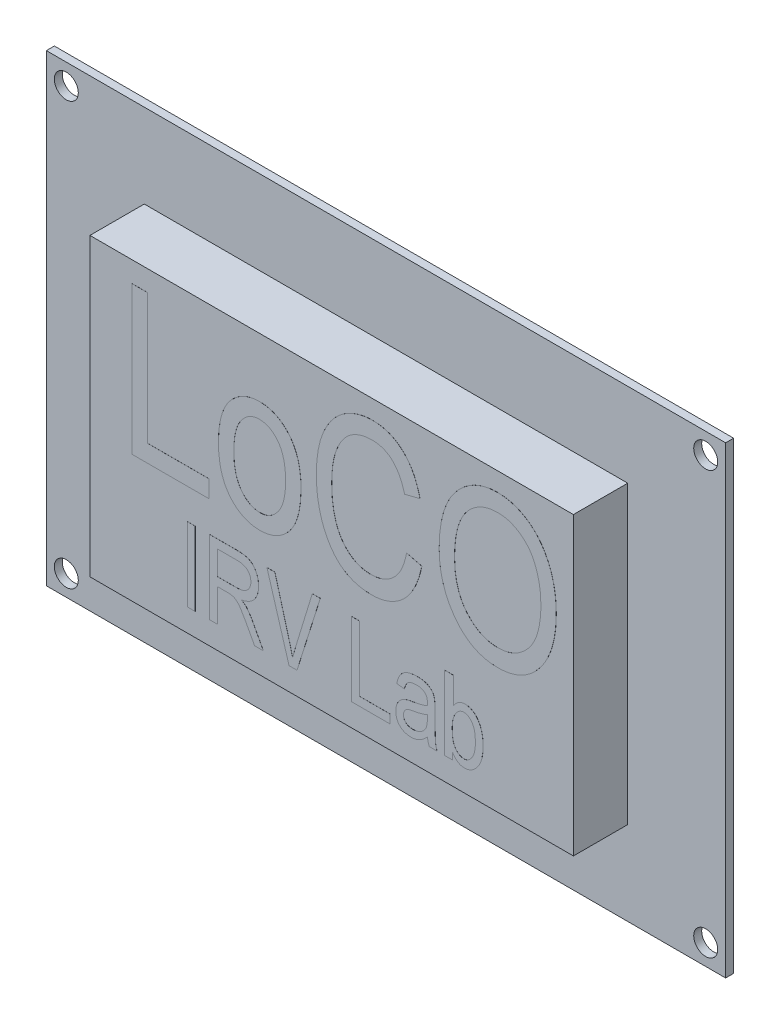
from build123d import *

# Parameters (mm, degrees)
SKETCH2_W           = 85
SKETCH2_H           = 58
SKETCH2_R           = 1.5
BOSS_EXTRUDE1_DEPTH = 1
SKETCH3_W           = 60.5
SKETCH3_H           = 37
BOSS_EXTRUDE2_DEPTH = 6.8
BOSS_EXTRUDE3_DEPTH = 0.01
SKETCH7_W           = 0.960617898
SKETCH7_H           = 9.245947265
BOSS_EXTRUDE4_DEPTH = 0.01


with BuildPart() as part:
    # Sketch2 → Boss-Extrude1 (new body)
    with BuildSketch(Plane.XY):
        Rectangle(SKETCH2_W, SKETCH2_H)
        with Locations((-40.005, 26.415)):
            Circle(SKETCH2_R, mode=Mode.SUBTRACT)
        with Locations((-40.005, -26.417)):
            Circle(SKETCH2_R, mode=Mode.SUBTRACT)
        with Locations((40.005, -26.417)):
            Circle(SKETCH2_R, mode=Mode.SUBTRACT)
        with Locations((40.005, 26.415)):
            Circle(SKETCH2_R, mode=Mode.SUBTRACT)
    extrude(amount=BOSS_EXTRUDE1_DEPTH)

    # Sketch3 → Boss-Extrude2 (add)
    with BuildSketch(Plane.XY.offset(1)):
        Rectangle(SKETCH3_W, SKETCH3_H)
    extrude(amount=BOSS_EXTRUDE2_DEPTH)

    # Sketch6 → Boss-Extrude3 (add)
    with BuildSketch(Plane.XY.offset(7.8)):
        Polygon((-24.963170893, -2.578067019), (-24.963170893, 15.913827512), (-23.041935097, 15.913827512), (-23.041935097, -0.416676749), (-15.356991915, -0.416676749), (-15.356991915, -2.578067019), align=None)
        with BuildLine():
            add(Edge.make_bspline(
                [(-14.156219543, 4.146258265), (-14.15200696, 4.42530417), (-14.143833079, 4.966750577), (-14.077886357, 5.752032324), (-13.959388452, 6.483464237), (-13.806933902, 7.164302864), (-13.597996615, 7.791479774), (-13.349059179, 8.367491571), (-13.05094873, 8.889941904), (-12.708280505, 9.357113515), (-12.329198324, 9.768007717), (-11.926500768, 10.129361278), (-11.495391443, 10.430018117), (-11.043726239, 10.680740051), (-10.565643457, 10.87298786), (-10.063826958, 11.012499727), (-9.536112732, 11.096979035), (-9.175826053, 11.106104677), (-8.992898343, 11.110738023)],
                knots=[0, 0, 0, 0, 0.000837091, 0.001624249, 0.002361452, 0.003058685, 0.003714885, 0.004341639, 0.00493832, 0.005515473, 0.00607584, 0.006612763, 0.00713536, 0.007649263, 0.008159329, 0.008677352, 0.009209137, 0.009757619, 0.009757619, 0.009757619, 0.009757619], degree=3))
            add(Edge.make_bspline(
                [(-8.992898343, 11.110738023), (-8.812454083, 11.106205822), (-8.45834284, 11.097311643), (-7.938284473, 11.011669197), (-7.441705544, 10.872185185), (-6.965245286, 10.681817127), (-6.51609778, 10.428798594), (-6.085429031, 10.129588058), (-5.682439834, 9.767132369), (-5.301595354, 9.356527716), (-4.948921739, 8.895576641), (-4.651580836, 8.377372416), (-4.392704216, 7.814603207), (-4.189901258, 7.200704027), (-4.027950751, 6.540739186), (-3.913626128, 5.831799777), (-3.840605578, 5.074639691), (-3.833318488, 4.55294606), (-3.829577143, 4.28509757)],
                knots=[0, 0, 0, 0, 0.000540986, 0.001061652, 0.001576062, 0.002086128, 0.002596746, 0.003119343, 0.003656266, 0.004219178, 0.004797804, 0.005393115, 0.006007698, 0.006653222, 0.007329428, 0.008044408, 0.008805741, 0.009609073, 0.009609073, 0.009609073, 0.009609073], degree=3))
            add(Edge.make_bspline(
                [(-3.829577143, 4.28509757), (-3.83372774, 3.994794579), (-3.841754786, 3.433363293), (-3.908109211, 2.619427655), (-4.025777942, 1.864125963), (-4.178326976, 1.163278066), (-4.387336273, 0.522890075), (-4.632431151, -0.064253775), (-4.930172263, -0.592879833), (-5.272899155, -1.062810828), (-5.649105151, -1.476632145), (-6.051936918, -1.836727908), (-6.482906541, -2.137421542), (-6.935419002, -2.38921361), (-7.415486962, -2.579641695), (-7.918160424, -2.72012531), (-8.447185117, -2.804625323), (-8.808721004, -2.813632808), (-8.992898343, -2.818221494)],
                knots=[0, 0, 0, 0, 0.000870851, 0.001684182, 0.002447335, 0.003162856, 0.003833321, 0.004465478, 0.005068683, 0.005648865, 0.006206701, 0.006743624, 0.007266221, 0.007780124, 0.00829367, 0.008811694, 0.009343478, 0.009895708, 0.009895708, 0.009895708, 0.009895708], degree=3))
            add(Edge.make_bspline(
                [(-8.992898343, -2.818221494), (-9.173331556, -2.81355127), (-9.529892967, -2.80432225), (-10.05251669, -2.719760071), (-10.552643117, -2.58083849), (-11.027707661, -2.383398411), (-11.480083611, -2.135215604), (-11.909446242, -1.830660104), (-12.313207009, -1.469511051), (-12.692990872, -1.055936489), (-13.040862365, -0.589629356), (-13.340095479, -0.066175863), (-13.591659287, 0.511019439), (-13.801340629, 1.137236224), (-13.96261011, 1.816713799), (-14.070766036, 2.547504727), (-14.14577011, 3.329183176), (-14.152665912, 3.86838829), (-14.156219543, 4.146258265)],
                knots=[0, 0, 0, 0, 0.000540986, 0.001069064, 0.001583473, 0.002094959, 0.002608861, 0.003128391, 0.003670612, 0.004230979, 0.004810359, 0.005412163, 0.006035482, 0.006696429, 0.007390868, 0.008127489, 0.008911241, 0.009744581, 0.009744581, 0.009744581, 0.009744581], degree=3))
        make_face()
        with BuildLine():
            add(Edge.make_bspline(
                [(-12.234983748, 4.153763092), (-12.232450504, 3.947271009), (-12.22754643, 3.547525544), (-12.180120634, 2.969084748), (-12.113343146, 2.430334113), (-12.00606319, 1.934564649), (-11.877548363, 1.476014822), (-11.712396377, 1.060669531), (-11.520425586, 0.683823899), (-11.298972448, 0.349838158), (-11.054872356, 0.0565262), (-10.794382089, -0.195948995), (-10.52274285, -0.412699242), (-10.23659641, -0.591301609), (-9.933058714, -0.727053311), (-9.61555828, -0.82456985), (-9.284309685, -0.88743544), (-9.058221732, -0.893782426), (-8.944116965, -0.896985698)],
                knots=[0, 0, 0, 0, 0.00061933, 0.001198954, 0.001740264, 0.002246604, 0.002719259, 0.003167307, 0.003585192, 0.003985876, 0.00436687, 0.004727766, 0.005072355, 0.005407666, 0.005736854, 0.00606681, 0.006402436, 0.006744421, 0.006744421, 0.006744421, 0.006744421], degree=3))
            add(Edge.make_bspline(
                [(-8.944116965, -0.896985698), (-8.836248049, -0.893786928), (-8.622535141, -0.887449435), (-8.309930092, -0.824513726), (-8.00832716, -0.72615972), (-7.71954674, -0.586973684), (-7.44336105, -0.406516858), (-7.175100581, -0.193417028), (-6.923411566, 0.065787255), (-6.684208241, 0.361687579), (-6.460497765, 0.695665177), (-6.269875095, 1.074180599), (-6.109114441, 1.491833763), (-5.979996093, 1.948333242), (-5.872038561, 2.442767551), (-5.805980242, 2.979120773), (-5.758289445, 3.553770423), (-5.753354887, 3.949770653), (-5.750812938, 4.153763092)],
                knots=[0, 0, 0, 0, 0.000323253, 0.000640437, 0.00095252, 0.001273082, 0.001598873, 0.001940528, 0.002298741, 0.002680253, 0.003080936, 0.00350216, 0.003948839, 0.004421494, 0.004924164, 0.005465475, 0.006041357, 0.006653185, 0.006653185, 0.006653185, 0.006653185], degree=3))
            add(Edge.make_bspline(
                [(-5.750812938, 4.153763092), (-5.753353214, 4.35900363), (-5.758269954, 4.756249493), (-5.80557462, 5.330962967), (-5.87289182, 5.867125225), (-5.979254359, 6.360555409), (-6.10792087, 6.816749727), (-6.275489292, 7.229587999), (-6.463064833, 7.607524387), (-6.687989894, 7.939496376), (-6.932056998, 8.232258091), (-7.190145137, 8.48853281), (-7.463202427, 8.705059774), (-7.749161727, 8.883858609), (-8.052748237, 9.019559063), (-8.370235615, 9.11708931), (-8.701487719, 9.179951215), (-8.927575195, 9.186298702), (-9.041679721, 9.189502228)],
                knots=[0, 0, 0, 0, 0.000615579, 0.001191461, 0.001729053, 0.002235392, 0.002704444, 0.003149006, 0.00357023, 0.003967791, 0.004348786, 0.004712305, 0.005056895, 0.005392206, 0.005721393, 0.00605135, 0.006386976, 0.006728961, 0.006728961, 0.006728961, 0.006728961], degree=3))
            add(Edge.make_bspline(
                [(-9.041679721, 9.189502228), (-9.150810717, 9.18639516), (-9.365797338, 9.180274276), (-9.680732178, 9.11656275), (-9.983174033, 9.018904419), (-10.274991847, 8.882571941), (-10.55408203, 8.705255233), (-10.81718142, 8.484299147), (-11.068748391, 8.227254057), (-11.310841244, 7.935424159), (-11.52716356, 7.599917761), (-11.720194208, 7.226253856), (-11.880692311, 6.810797866), (-12.010671335, 6.355937077), (-12.111995092, 5.861652701), (-12.1805457, 5.327284399), (-12.227334357, 4.753723985), (-12.23238302, 4.357744727), (-12.234983748, 4.153763092)],
                knots=[0, 0, 0, 0, 0.000326999, 0.000644183, 0.000959832, 0.001278787, 0.001607739, 0.001948858, 0.002307071, 0.002685675, 0.003084297, 0.003502182, 0.003945364, 0.004418019, 0.004919918, 0.005457509, 0.006033392, 0.006645219, 0.006645219, 0.006645219, 0.006645219], degree=3))
        make_face(mode=Mode.SUBTRACT)
        with BuildLine():
            Line((9.378918951, 3.90610379), (11.300154747, 3.425794842))
            add(Edge.make_bspline(
                [(11.300154747, 3.425794842), (11.242891984, 3.171195833), (11.131253485, 2.67483398), (10.921856518, 1.960903479), (10.677171533, 1.298320529), (10.403899049, 0.684575004), (10.099847744, 0.119572764), (9.766514302, -0.396297564), (9.401092804, -0.862614323), (9.001763057, -1.273635186), (8.581855362, -1.642429765), (8.131589248, -1.951997003), (7.664511209, -2.22330435), (7.171696954, -2.439388925), (6.658120736, -2.610538041), (6.121017661, -2.728604713), (5.562570016, -2.807723869), (5.181497307, -2.814693437), (4.988594965, -2.818221494)],
                knots=[0, 0, 0, 0, 0.000782745, 0.001526026, 0.002230051, 0.002900233, 0.003539917, 0.004152952, 0.004740753, 0.005313976, 0.005869954, 0.006414378, 0.006950553, 0.007488144, 0.008025683, 0.008571888, 0.009136012, 0.009714322, 0.009714322, 0.009714322, 0.009714322], degree=3))
            add(Edge.make_bspline(
                [(4.988594965, -2.818221494), (4.81834251, -2.815872259), (4.484607751, -2.811267208), (3.993471036, -2.759209824), (3.520035056, -2.683170333), (3.065395889, -2.568691242), (2.628552016, -2.428545701), (2.213721161, -2.248558067), (1.814162689, -2.043719818), (1.434449818, -1.801642875), (1.070071269, -1.527400983), (0.730805893, -1.208537913), (0.400243033, -0.859984297), (0.095322455, -0.465085077), (-0.204654032, -0.039584319), (-0.474337021, 0.432427386), (-0.735961693, 0.93714066), (-0.976896507, 1.4786138), (-1.201311201, 2.05140184), (-1.384574701, 2.656355206), (-1.548025031, 3.282945285), (-1.677747425, 3.936028511), (-1.784779462, 4.612891574), (-1.852558442, 5.31720806), (-1.90046331, 6.045568257), (-1.905685973, 6.540215103), (-1.908341347, 6.791709897)],
                knots=[0, 0, 0, 0, 0.000510549, 0.001000796, 0.001480122, 0.001947911, 0.002405951, 0.002854816, 0.003302927, 0.003751603, 0.004204154, 0.004668863, 0.005146733, 0.005643697, 0.006164148, 0.006707328, 0.007272898, 0.007869166, 0.008484493, 0.009117095, 0.009764188, 0.010426507, 0.011113773, 0.011819087, 0.012548447, 0.013302831, 0.013302831, 0.013302831, 0.013302831], degree=3))
            add(Edge.make_bspline(
                [(-1.908341347, 6.791709897), (-1.905707656, 7.039454752), (-1.900542166, 7.525359656), (-1.852715737, 8.238728047), (-1.785109223, 8.924369484), (-1.677700067, 9.579930681), (-1.548865058, 10.208264244), (-1.386024855, 10.805188528), (-1.200019012, 11.375614435), (-0.978835724, 11.914086842), (-0.729590688, 12.421034838), (-0.463251486, 12.898567852), (-0.179200745, 13.346729203), (0.129063121, 13.760927932), (0.459894368, 14.140135586), (0.810607883, 14.488149668), (1.183024834, 14.802805655), (1.572836044, 15.089797288), (1.981322581, 15.338530766), (2.400059856, 15.559420008), (2.832197948, 15.742698545), (3.276159764, 15.893306221), (3.731516184, 16.010377913), (4.198438775, 16.090870372), (4.675751684, 16.147643686), (4.998431647, 16.151856735), (5.161205994, 16.153981986)],
                knots=[0, 0, 0, 0, 0.00074313, 0.001457509, 0.002144159, 0.002809184, 0.003449452, 0.004067519, 0.004664389, 0.005248332, 0.005812206, 0.006358179, 0.006888014, 0.007402848, 0.007905517, 0.008396395, 0.008883588, 0.009366936, 0.00984704, 0.010316991, 0.010786058, 0.011253591, 0.011722298, 0.012194864, 0.012674307, 0.013162352, 0.013162352, 0.013162352, 0.013162352], degree=3))
            add(Edge.make_bspline(
                [(5.161205994, 16.153981986), (5.338979024, 16.149379478), (5.688185591, 16.140338589), (6.203979813, 16.077027341), (6.697394832, 15.961878993), (7.176730584, 15.813529312), (7.632991827, 15.612986256), (8.072073678, 15.371718091), (8.4901465, 15.084639533), (8.887483281, 14.753518824), (9.263652631, 14.382454688), (9.61013372, 13.967559972), (9.923763583, 13.510674107), (10.216731064, 13.018194216), (10.469060884, 12.478116787), (10.696570157, 11.899939589), (10.903711868, 11.282675352), (11.00702934, 10.851495338), (11.060000272, 10.630429074)],
                knots=[0, 0, 0, 0, 0.000533318, 0.001047618, 0.001555568, 0.002051625, 0.002550752, 0.003047887, 0.003552681, 0.004069643, 0.004597668, 0.00513577, 0.005688496, 0.006258691, 0.006852865, 0.007474419, 0.008122316, 0.008803987, 0.008803987, 0.008803987, 0.008803987], degree=3))
            Line((11.060000272, 10.630429074), (9.138764477, 10.150120126))
            add(Edge.make_bspline(
                [(9.138764477, 10.150120126), (9.095340635, 10.305706881), (9.010651095, 10.609147806), (8.859943659, 11.044981467), (8.695111189, 11.451057618), (8.515970021, 11.828472598), (8.316481805, 12.173951396), (8.10247705, 12.490309359), (7.873589465, 12.77842719), (7.625011427, 13.032229672), (7.365015968, 13.261230412), (7.085636003, 13.457405204), (6.789191198, 13.621291094), (6.478360354, 13.759057134), (6.152161213, 13.86268177), (5.809521155, 13.93900893), (5.45135091, 13.984030592), (5.206360359, 13.989715426), (5.082405307, 13.992591717)],
                knots=[0, 0, 0, 0, 0.000484512, 0.000944944, 0.001382547, 0.001798777, 0.002197188, 0.002578108, 0.002943791, 0.00329938, 0.003642495, 0.003981876, 0.004321195, 0.00465724, 0.005000191, 0.005346146, 0.005709182, 0.006080974, 0.006080974, 0.006080974, 0.006080974], degree=3))
            add(Edge.make_bspline(
                [(5.082405307, 13.992591717), (4.837742501, 13.983527205), (4.360320146, 13.965839187), (3.669822746, 13.81870777), (3.027353904, 13.583365445), (2.538367893, 13.300968942), (2.175813823, 13.030108462), (1.918829142, 12.798543546), (1.676855588, 12.540030658), (1.446947434, 12.25703154), (1.229166146, 11.94723148), (1.032773437, 11.606858969), (0.842307438, 11.245570288), (0.670677214, 10.855653403), (0.517777755, 10.439252345), (0.38178282, 9.997268251), (0.265793877, 9.528918919), (0.172231683, 9.032778788), (0.102665181, 8.510250648), (0.049029802, 7.960904655), (0.020229812, 7.384900699), (0.015369577, 6.991866837), (0.012894448, 6.791709897)],
                knots=[0, 0, 0, 0, 0.000733345, 0.001431011, 0.002107799, 0.002778485, 0.003116202, 0.003464288, 0.003814692, 0.004177455, 0.004557414, 0.004949339, 0.005355502, 0.005782223, 0.006226246, 0.006685591, 0.007168852, 0.007672976, 0.008199411, 0.008749777, 0.009328428, 0.009928919, 0.009928919, 0.009928919, 0.009928919], degree=3))
            add(Edge.make_bspline(
                [(0.012894448, 6.791709897), (0.017640417, 6.491422667), (0.026845573, 5.90899342), (0.085541216, 5.063116161), (0.188232578, 4.274249793), (0.3389836, 3.545024047), (0.525193112, 2.873092353), (0.751745808, 2.258197682), (1.027229345, 1.702921596), (1.341956148, 1.206108999), (1.693117093, 0.768118446), (2.071998531, 0.386511124), (2.480991656, 0.065185681), (2.915129026, -0.201987259), (3.38087477, -0.404073192), (3.871689413, -0.551895533), (4.391337528, -0.6395852), (4.746854491, -0.650998155), (4.928556347, -0.656831224)],
                knots=[0, 0, 0, 0, 0.000900861, 0.001747286, 0.002542266, 0.003285547, 0.003979328, 0.004632399, 0.005248275, 0.005835381, 0.00639328, 0.006929258, 0.00744498, 0.007950164, 0.008454232, 0.008963525, 0.0094848, 0.010029727, 0.010029727, 0.010029727, 0.010029727], degree=3))
            add(Edge.make_bspline(
                [(4.928556347, -0.656831224), (5.063826777, -0.653110867), (5.330391938, -0.645779499), (5.723382007, -0.59101568), (6.103508182, -0.506334954), (6.469807269, -0.382053739), (6.818334208, -0.218242521), (7.156121875, -0.027523751), (7.47619159, 0.204879925), (7.783018769, 0.469281868), (8.070292258, 0.771688504), (8.332911435, 1.111782777), (8.57483811, 1.486793144), (8.782379904, 1.902917469), (8.971104002, 2.351435727), (9.135849669, 2.836482131), (9.274928691, 3.358053929), (9.343698119, 3.720482827), (9.378918951, 3.90610379)],
                knots=[0, 0, 0, 0, 0.000405695, 0.000799466, 0.001188162, 0.001572634, 0.001957105, 0.002342016, 0.002734605, 0.003141616, 0.003555676, 0.003983517, 0.004429028, 0.004892204, 0.005376557, 0.005888001, 0.006427749, 0.006994401, 0.006994401, 0.006994401, 0.006994401], degree=3))
        make_face()
        with BuildLine():
            add(Edge.make_bspline(
                [(13.461545016, 6.423973358), (13.468076656, 6.803167112), (13.480796167, 7.541597248), (13.57775289, 8.615207931), (13.742453034, 9.620928945), (13.968655831, 10.559725719), (14.265862539, 11.429910189), (14.625237359, 12.234860717), (15.054539922, 12.97082865), (15.547494094, 13.634587309), (16.085222571, 14.227352219), (16.664061654, 14.741118555), (17.271823275, 15.180473285), (17.916041146, 15.533834039), (18.588420674, 15.818077216), (19.298362564, 16.008324633), (20.037455699, 16.135505617), (20.541803204, 16.147765879), (20.797513728, 16.153981986)],
                knots=[0, 0, 0, 0, 0.001137483, 0.002215099, 0.003230506, 0.004192486, 0.005108583, 0.005985275, 0.006832864, 0.007659162, 0.008461337, 0.009229482, 0.009977146, 0.01070608, 0.01142943, 0.012161372, 0.012906583, 0.013672995, 0.013672995, 0.013672995, 0.013672995], degree=3))
            add(Edge.make_bspline(
                [(20.797513728, 16.153981986), (20.965274718, 16.15026731), (21.296616126, 16.142930525), (21.787987196, 16.087680997), (22.267958747, 16.004172763), (22.736111383, 15.877123773), (23.195006199, 15.721049487), (23.641227214, 15.52527418), (24.075079387, 15.293564801), (24.498329741, 15.033288504), (24.904488732, 14.735471328), (25.29039015, 14.405210278), (25.656589017, 14.043860215), (25.997246426, 13.64856494), (26.31803858, 13.223081327), (26.613619566, 12.76447276), (26.888031045, 12.273884415), (27.142497803, 11.754605952), (27.371528405, 11.206178559), (27.571700634, 10.631530789), (27.733918252, 10.028616473), (27.875175537, 9.403345373), (27.977408043, 8.749877554), (28.057862306, 8.072966066), (28.102381734, 7.368933231), (28.108072776, 6.891831968), (28.110967957, 6.649118178)],
                knots=[0, 0, 0, 0, 0.000503173, 0.000993808, 0.001481809, 0.001963304, 0.002447467, 0.002934775, 0.003423253, 0.003922041, 0.00442415, 0.004932502, 0.005444607, 0.00596599, 0.006496582, 0.007041974, 0.007601436, 0.008182091, 0.008775839, 0.009383428, 0.010006103, 0.010647952, 0.011305567, 0.01198931, 0.012692455, 0.013420578, 0.013420578, 0.013420578, 0.013420578], degree=3))
            add(Edge.make_bspline(
                [(28.110967957, 6.649118178), (28.104930185, 6.317501513), (28.093106915, 5.668123977), (28.008691112, 4.71700302), (27.855177803, 3.814203804), (27.65780352, 2.955109261), (27.389016305, 2.146444006), (27.065414747, 1.384120771), (26.685790505, 0.665954831), (26.379404799, 0.225882247), (26.227256298, 0.007345995)],
                knots=[0, 0, 0, 0, 0.000994843, 0.001948118, 0.00286112, 0.003740338, 0.00458996, 0.005413783, 0.006222983, 0.007021225, 0.007021225, 0.007021225, 0.007021225], degree=3))
            add(Edge.make_bspline(
                [(26.227256298, 0.007345995), (26.051739025, -0.216740105), (25.708669651, -0.654743022), (25.125152864, -1.23386052), (24.501272399, -1.722901223), (23.838139063, -2.128324587), (23.131158337, -2.435387954), (22.385952551, -2.658999218), (21.599066528, -2.792606485), (21.06069858, -2.809572687), (20.786256487, -2.818221494)],
                knots=[0, 0, 0, 0, 0.000853309, 0.001667894, 0.002459075, 0.003226818, 0.003993018, 0.004764684, 0.005556159, 0.00637917, 0.00637917, 0.00637917, 0.00637917], degree=3))
            add(Edge.make_bspline(
                [(20.786256487, -2.818221494), (20.510525711, -2.809874681), (19.969387732, -2.793493567), (19.177250251, -2.655180086), (18.427965899, -2.425405812), (17.717491308, -2.108520466), (17.053048559, -1.694595438), (16.431031707, -1.190457628), (15.847483973, -0.598588945), (15.507862405, -0.14818281), (15.333999434, 0.082394268)],
                knots=[0, 0, 0, 0, 0.000826758, 0.001622562, 0.002403587, 0.003172832, 0.003949654, 0.0047449, 0.005570132, 0.006435713, 0.006435713, 0.006435713, 0.006435713], degree=3))
            add(Edge.make_bspline(
                [(15.333999434, 0.082394268), (15.183597938, 0.305043114), (14.883685192, 0.749022915), (14.505346398, 1.461671169), (14.18082586, 2.205004468), (13.920039956, 2.984356052), (13.711063974, 3.795194392), (13.566707837, 4.641100808), (13.479029409, 5.521533637), (13.467437812, 6.119822514), (13.461545016, 6.423973358)],
                knots=[0, 0, 0, 0, 0.000805581, 0.001606394, 0.002416429, 0.003236389, 0.004069138, 0.00492602, 0.005808316, 0.006720647, 0.006720647, 0.006720647, 0.006720647], degree=3))
        make_face()
        with BuildLine():
            add(Edge.make_bspline(
                [(15.382780812, 6.393954049), (15.38823568, 6.122385412), (15.398838144, 5.594545613), (15.469014786, 4.825413661), (15.592398068, 4.102749711), (15.765040829, 3.426622987), (15.980099626, 2.795053164), (16.25281641, 2.213863163), (16.572371556, 1.677529717), (16.939703581, 1.19030808), (17.343730465, 0.758411446), (17.768500646, 0.377880638), (18.219333125, 0.062741702), (18.685511833, -0.204443048), (19.177265174, -0.408576104), (19.690527424, -0.549761025), (20.22401064, -0.639603803), (20.587018586, -0.651031576), (20.771246832, -0.656831224)],
                knots=[0, 0, 0, 0, 0.000814697, 0.001583503, 0.00231453, 0.003011672, 0.003675043, 0.004312953, 0.004933964, 0.005544858, 0.006139589, 0.006705806, 0.007252385, 0.007786705, 0.00831493, 0.008844805, 0.009380888, 0.009933309, 0.009933309, 0.009933309, 0.009933309], degree=3))
            add(Edge.make_bspline(
                [(20.771246832, -0.656831224), (20.959188675, -0.650849717), (21.33081792, -0.639022108), (21.876284893, -0.551478002), (22.398308484, -0.405631148), (22.894024431, -0.194957448), (23.368252203, 0.067317866), (23.81868022, 0.389980721), (24.24370163, 0.772396532), (24.645300396, 1.209844899), (25.008933494, 1.706679394), (25.330761395, 2.257083534), (25.596347567, 2.866332407), (25.811419361, 3.529422927), (25.986438584, 4.245091017), (26.101142839, 5.01763666), (26.180057082, 5.843210453), (26.186445497, 6.412513508), (26.189732161, 6.705404383)],
                knots=[0, 0, 0, 0, 0.000563662, 0.001114564, 0.001652679, 0.002185813, 0.002726681, 0.003275432, 0.003844143, 0.004439087, 0.005053761, 0.005687697, 0.006347973, 0.007043335, 0.007776891, 0.008555451, 0.009384386, 0.01026274, 0.01026274, 0.01026274, 0.01026274], degree=3))
            add(Edge.make_bspline(
                [(26.189732161, 6.705404383), (26.187898456, 6.898086768), (26.184286927, 7.277579561), (26.145778893, 7.839934213), (26.081222626, 8.385536758), (25.998013872, 8.917690698), (25.87744337, 9.430690143), (25.746198689, 9.932518007), (25.579717089, 10.41642677), (25.450784802, 10.729847734), (25.386715637, 10.885593204)],
                knots=[0, 0, 0, 0, 0.000577981, 0.001138349, 0.001689903, 0.002225986, 0.002753063, 0.003270093, 0.003781538, 0.004286722, 0.004286722, 0.004286722, 0.004286722], degree=3))
            add(Edge.make_bspline(
                [(25.386715637, 10.885593204), (25.278453022, 11.11338157), (25.064509788, 11.56352569), (24.627102618, 12.165889883), (24.120767597, 12.704102828), (23.536186058, 13.155497875), (22.905458949, 13.529857942), (22.234135247, 13.799449474), (21.532048513, 13.962833129), (21.053534436, 13.982623825), (20.812523382, 13.992591717)],
                knots=[0, 0, 0, 0, 0.000755205, 0.001492399, 0.002222309, 0.002965438, 0.003700394, 0.004416014, 0.005127876, 0.005850252, 0.005850252, 0.005850252, 0.005850252], degree=3))
            add(Edge.make_bspline(
                [(20.812523382, 13.992591717), (20.619595762, 13.986614781), (20.239284291, 13.974832656), (19.682384502, 13.88798524), (19.152667587, 13.740537147), (18.649709184, 13.535490624), (18.170156479, 13.277391021), (17.720476195, 12.952782051), (17.296039837, 12.573464277), (16.900895934, 12.134891148), (16.536316221, 11.64052475), (16.23168561, 11.072883908), (15.962863058, 10.450357573), (15.752180616, 9.759866815), (15.58171818, 9.0089934), (15.47245053, 8.192551679), (15.391782044, 7.31490008), (15.385851402, 6.708116312), (15.382780812, 6.393954049)],
                knots=[0, 0, 0, 0, 0.000578651, 0.001140674, 0.001686015, 0.002224653, 0.002767003, 0.003315755, 0.003884465, 0.004471583, 0.005084043, 0.005722229, 0.006399714, 0.007115363, 0.007884608, 0.008707149, 0.009584676, 0.010526801, 0.010526801, 0.010526801, 0.010526801], degree=3))
        make_face(mode=Mode.SUBTRACT)
    extrude(amount=BOSS_EXTRUDE3_DEPTH)

    # Sketch7 → Boss-Extrude4 (add)
    with BuildSketch(Plane.XY.offset(7.8)):
        with Locations((-17.545320312, -11.032828223)):
            Rectangle(SKETCH7_W, SKETCH7_H)
        with BuildLine():
            Line((-15.263852805, -15.655801855), (-15.263852805, -6.40985459))
            Line((-15.263852805, -6.40985459), (-11.86791844, -6.40985459))
            add(Edge.make_bspline(
                [(-11.86791844, -6.40985459), (-11.782218222, -6.41034789), (-11.616336629, -6.411302725), (-11.376033114, -6.425038557), (-11.152588407, -6.445371926), (-10.946300199, -6.472407383), (-10.758372742, -6.509889219), (-10.588060775, -6.555357374), (-10.433978736, -6.606109345), (-10.253092248, -6.689825181), (-10.046723685, -6.819676737), (-9.824155339, -7.017512143), (-9.629203613, -7.262505761), (-9.45572549, -7.543993753), (-9.313259892, -7.860038126), (-9.212345141, -8.204703709), (-9.151424892, -8.57346203), (-9.143817506, -8.827421747), (-9.139913707, -8.957743467)],
                knots=[0, 0, 0, 0, 0.000257068, 0.000497581, 0.000721802, 0.000930094, 0.001121431, 0.00129619, 0.001458761, 0.001607361, 0.001893148, 0.002186851, 0.002496283, 0.002829012, 0.003176678, 0.003532861, 0.003903615, 0.004294411, 0.004294411, 0.004294411, 0.004294411], degree=3))
            add(Edge.make_bspline(
                [(-9.139913707, -8.957743467), (-9.141954823, -9.044104333), (-9.14594176, -9.212794099), (-9.170093567, -9.460038195), (-9.21206383, -9.694562212), (-9.276250143, -9.9157593), (-9.350690529, -10.126378205), (-9.448440338, -10.322726902), (-9.560589618, -10.507341228), (-9.690938909, -10.678753808), (-9.836739376, -10.836582404), (-10.000370018, -10.978346146), (-10.178649192, -11.106058026), (-10.372966985, -11.218596664), (-10.582120782, -11.317402578), (-10.808584582, -11.396245507), (-11.048828896, -11.465290323), (-11.215939348, -11.496959621), (-11.301303976, -11.513137171)],
                knots=[0, 0, 0, 0, 0.000259086, 0.000506077, 0.00074454, 0.00097262, 0.001196393, 0.001413717, 0.00162931, 0.001843575, 0.002058645, 0.002272738, 0.002491933, 0.00271558, 0.002945559, 0.003184722, 0.003434194, 0.00369471, 0.00369471, 0.00369471, 0.00369471], degree=3))
            add(Edge.make_bspline(
                [(-11.301303976, -11.513137171), (-11.2382962, -11.547997847), (-11.118353847, -11.614359043), (-10.95420836, -11.721426481), (-10.8139272, -11.829195133), (-10.734624963, -11.907619725), (-10.697165377, -11.944664743)],
                knots=[0, 0, 0, 0, 0.000215959, 0.000411103, 0.000587506, 0.000745431, 0.000745431, 0.000745431, 0.000745431], degree=3))
            add(Edge.make_bspline(
                [(-10.697165377, -11.944664743), (-10.622241057, -12.035101405), (-10.471549898, -12.216991685), (-10.264976296, -12.507174821), (-10.067105999, -12.809046451), (-9.950907244, -13.021397581), (-9.892272646, -13.128551253)],
                knots=[0, 0, 0, 0, 0.000352208, 0.000708376, 0.001067986, 0.001434284, 0.001434284, 0.001434284, 0.001434284], degree=3))
            Line((-9.892272646, -13.128551253), (-8.53952752, -15.655801855))
            Line((-8.53952752, -15.655801855), (-9.631479896, -15.655801855))
            Line((-9.631479896, -15.655801855), (-10.699041584, -13.678279855))
            add(Edge.make_bspline(
                [(-10.699041584, -13.678279855), (-10.748773447, -13.585556451), (-10.84389863, -13.408198715), (-10.985074273, -13.156376883), (-11.116306917, -12.929270898), (-11.237374937, -12.726659267), (-11.350072517, -12.550691487), (-11.451291355, -12.398949511), (-11.543988999, -12.273161371), (-11.654933405, -12.143561598), (-11.783888253, -12.009218178), (-11.937184209, -11.874295275), (-12.09030212, -11.769700299), (-12.246197138, -11.690047842), (-12.417804071, -11.637575161), (-12.611171311, -11.598298685), (-12.834948298, -11.576935251), (-12.99360106, -11.574481976), (-13.078071846, -11.57317579)],
                knots=[0, 0, 0, 0, 0.000315649, 0.000603761, 0.000866035, 0.001102534, 0.001311762, 0.001492853, 0.001649704, 0.001780151, 0.002004395, 0.002207901, 0.002391597, 0.00255941, 0.002730885, 0.00292811, 0.003150644, 0.003404043, 0.003404043, 0.003404043, 0.003404043], degree=3))
            Line((-13.078071846, -11.57317579), (-14.303234907, -11.57317579))
            Line((-14.303234907, -11.57317579), (-14.303234907, -15.655801855))
            Line((-14.303234907, -15.655801855), (-15.263852805, -15.655801855))
        make_face()
        with BuildLine():
            Line((-14.303234907, -10.492480655), (-12.049910502, -10.492480655))
            add(Edge.make_bspline(
                [(-12.049910502, -10.492480655), (-11.934150889, -10.490225648), (-11.717206079, -10.485999544), (-11.413700352, -10.457932092), (-11.154649522, -10.40714058), (-10.935214765, -10.333165063), (-10.748099876, -10.235144999), (-10.585191851, -10.113762507), (-10.442300066, -9.968796859), (-10.320755343, -9.801117574), (-10.220258723, -9.614386474), (-10.15243162, -9.409115296), (-10.106393303, -9.191188772), (-10.102517318, -9.040547464), (-10.100531604, -8.963372087)],
                knots=[0, 0, 0, 0, 0.000347281, 0.000650838, 0.000913192, 0.001137475, 0.001343089, 0.00154422, 0.001744553, 0.001951327, 0.00216367, 0.002377862, 0.002597899, 0.002829046, 0.002829046, 0.002829046, 0.002829046], degree=3))
            add(Edge.make_bspline(
                [(-10.100531604, -8.963372087), (-10.102265878, -8.90767489), (-10.105646891, -8.799091741), (-10.123435844, -8.640462133), (-10.158154623, -8.491187355), (-10.20396391, -8.350465248), (-10.265551833, -8.21958146), (-10.337471964, -8.096469979), (-10.428047065, -7.986192384), (-10.526613896, -7.881792436), (-10.640683089, -7.789109115), (-10.76806813, -7.708801103), (-10.908743341, -7.641340916), (-11.061358124, -7.583496596), (-11.229009999, -7.545020558), (-11.407769851, -7.511696209), (-11.599859838, -7.493220804), (-11.73217048, -7.491458283), (-11.800374994, -7.490549725)],
                knots=[0, 0, 0, 0, 0.000167151, 0.000325865, 0.000477884, 0.000626211, 0.000768914, 0.000911135, 0.001052661, 0.001195967, 0.00134131, 0.00149226, 0.001646657, 0.001808718, 0.001980727, 0.002161798, 0.002354088, 0.002558672, 0.002558672, 0.002558672, 0.002558672], degree=3))
            Line((-11.800374994, -7.490549725), (-14.303234907, -7.490549725))
            Line((-14.303234907, -7.490549725), (-14.303234907, -10.492480655))
        make_face(mode=Mode.SUBTRACT)
        with BuildLine():
            Line((-5.321832804, -15.655801855), (-8.087361674, -6.40985459))
            Line((-8.087361674, -6.40985459), (-7.098600674, -6.40985459))
            Line((-7.098600674, -6.40985459), (-5.248660738, -13.117294012))
            add(Edge.make_bspline(
                [(-5.248660738, -13.117294012), (-5.213943573, -13.245417283), (-5.145782965, -13.496963165), (-5.050859444, -13.86882383), (-4.960147257, -14.226246642), (-4.904409454, -14.460589321), (-4.877171785, -14.57510672)],
                knots=[0, 0, 0, 0, 0.000398225, 0.000781839, 0.001151337, 0.001504468, 0.001504468, 0.001504468, 0.001504468], degree=3))
            add(Edge.make_bspline(
                [(-4.877171785, -14.57510672), (-4.815454012, -14.335800948), (-4.689476588, -13.847333475), (-4.545401946, -13.363892006), (-4.47191111, -13.117294012)],
                knots=[0, 0, 0, 0, 0.000741339, 0.001513211, 0.001513211, 0.001513211, 0.001513211], degree=3))
            Line((-4.47191111, -13.117294012), (-2.415588422, -6.40985459))
            Line((-2.415588422, -6.40985459), (-1.417446388, -6.40985459))
            Line((-1.417446388, -6.40985459), (-4.329319391, -15.655801855))
            Line((-4.329319391, -15.655801855), (-5.321832804, -15.655801855))
        make_face()
        Polygon((2.507578303, -15.655801855), (2.507578303, -6.40985459), (3.468196201, -6.40985459), (3.468196201, -14.57510672), (7.310667792, -14.57510672), (7.310667792, -15.655801855), align=None)
        with BuildLine():
            add(Edge.make_bspline(
                [(11.993680043, -14.728955681), (11.914915265, -14.811571347), (11.761785969, -14.972187285), (11.516503508, -15.185302054), (11.266346382, -15.366794231), (11.010985338, -15.516262811), (10.750201355, -15.631483605), (10.485651206, -15.715472448), (10.21506651, -15.76572422), (10.032623191, -15.772486925), (9.94110977, -15.775879093)],
                knots=[0, 0, 0, 0, 0.000342293, 0.000665464, 0.000973214, 0.001268303, 0.001551387, 0.001826723, 0.002099419, 0.002373865, 0.002373865, 0.002373865, 0.002373865], degree=3))
            add(Edge.make_bspline(
                [(9.94110977, -15.775879093), (9.870351154, -15.774719894), (9.732140567, -15.772455669), (9.530245402, -15.746513964), (9.338776486, -15.708919865), (9.159001792, -15.651066926), (8.989072263, -15.580723417), (8.831169327, -15.491519427), (8.683223507, -15.388139482), (8.548894156, -15.267587623), (8.426500353, -15.135148475), (8.321121522, -14.989110882), (8.230310572, -14.833015495), (8.15682169, -14.664899694), (8.101350011, -14.485904739), (8.059297407, -14.296552359), (8.034916447, -14.096066598), (8.032409246, -13.958525675), (8.031131215, -13.88841502)],
                knots=[0, 0, 0, 0, 0.000212144, 0.000414375, 0.000609761, 0.000796677, 0.00097997, 0.001160564, 0.001339632, 0.001520372, 0.001700975, 0.00187961, 0.002059501, 0.002241812, 0.002428727, 0.002620835, 0.002823065, 0.003033334, 0.003033334, 0.003033334, 0.003033334], degree=3))
            add(Edge.make_bspline(
                [(8.031131215, -13.88841502), (8.033617135, -13.794998479), (8.038455957, -13.613164009), (8.087717075, -13.349270011), (8.163487223, -13.101273278), (8.273582035, -12.871407768), (8.409759976, -12.662407512), (8.569533433, -12.475132412), (8.752807226, -12.313171924), (8.924520028, -12.197772351), (9.077139748, -12.117737408), (9.206623664, -12.062161678), (9.34951173, -12.009903578), (9.50572468, -11.960476014), (9.676502599, -11.918511763), (9.861035239, -11.878854966), (10.059447201, -11.843436874), (10.196837473, -11.823562261), (10.267569758, -11.813330264)],
                knots=[0, 0, 0, 0, 0.000279957, 0.000544935, 0.000802474, 0.001055922, 0.001306752, 0.001548921, 0.001792141, 0.002038275, 0.002167516, 0.002308681, 0.002460642, 0.002623829, 0.002799933, 0.002987975, 0.003190022, 0.00340442, 0.00340442, 0.00340442, 0.00340442], degree=3))
            add(Edge.make_bspline(
                [(10.267569758, -11.813330264), (10.362742346, -11.797035135), (10.546658803, -11.765545579), (10.811017785, -11.710395878), (11.05657054, -11.654735415), (11.281434153, -11.5945283), (11.488496375, -11.535036079), (11.674808419, -11.471238324), (11.843091925, -11.407225583), (11.9452247, -11.356898321), (11.993680043, -11.333021316)],
                knots=[0, 0, 0, 0, 0.000289648, 0.00055973, 0.000810047, 0.001044873, 0.001258011, 0.001456179, 0.00163561, 0.001797584, 0.001797584, 0.001797584, 0.001797584], degree=3))
            Line((11.993680043, -11.333021316), (11.993680043, -11.059095118))
            add(Edge.make_bspline(
                [(11.993680043, -11.059095118), (11.993278839, -11.007142657), (11.99250882, -10.907431775), (11.977841999, -10.764176732), (11.960571237, -10.632200562), (11.93312235, -10.511868587), (11.894493666, -10.40457209), (11.852180823, -10.307366276), (11.800221796, -10.222176702), (11.757371759, -10.174215829), (11.736639708, -10.151011012)],
                knots=[0, 0, 0, 0, 0.00015577, 0.000298966, 0.000431633, 0.000554965, 0.000668301, 0.000773268, 0.000872707, 0.000965915, 0.000965915, 0.000965915, 0.000965915], degree=3))
            add(Edge.make_bspline(
                [(11.736639708, -10.151011012), (11.705513273, -10.120716059), (11.642509105, -10.059394925), (11.531948113, -9.982725564), (11.409596041, -9.917286664), (11.275866903, -9.862568156), (11.129903183, -9.820966255), (10.971234241, -9.794594442), (10.800926984, -9.774301802), (10.682904566, -9.772793415), (10.62217285, -9.772017232)],
                knots=[0, 0, 0, 0, 0.000130123, 0.000263386, 0.000401896, 0.00054579, 0.000696039, 0.000856133, 0.001027896, 0.001209975, 0.001209975, 0.001209975, 0.001209975], degree=3))
            add(Edge.make_bspline(
                [(10.62217285, -9.772017232), (10.515599842, -9.774000678), (10.316162209, -9.777712442), (10.037930966, -9.82782304), (9.800222178, -9.903162369), (9.632454269, -9.998824507), (9.521204167, -10.094956308), (9.444574392, -10.179046567), (9.375142955, -10.277952734), (9.31134556, -10.390112961), (9.251017748, -10.515003067), (9.199615925, -10.655747286), (9.149797973, -10.808563892), (9.12474929, -10.916898417), (9.11182635, -10.972789604)],
                knots=[0, 0, 0, 0, 0.000319308, 0.000597544, 0.000844954, 0.001064414, 0.001170847, 0.001285065, 0.001404804, 0.001532565, 0.001671873, 0.001820319, 0.001981716, 0.002153725, 0.002153725, 0.002153725, 0.002153725], degree=3))
            Line((9.11182635, -10.972789604), (8.151208453, -10.852712367))
            add(Edge.make_bspline(
                [(8.151208453, -10.852712367), (8.169637516, -10.766810669), (8.205547954, -10.599424645), (8.273982088, -10.358493928), (8.359167674, -10.13615612), (8.455757396, -9.931830343), (8.565692328, -9.745980682), (8.687125443, -9.577256444), (8.825580122, -9.429330793), (8.974559588, -9.29579017), (9.140294532, -9.180180814), (9.322204241, -9.080950027), (9.521579055, -8.999016249), (9.735600044, -8.928460341), (9.96786382, -8.877806799), (10.215713621, -8.837432449), (10.481064644, -8.815588611), (10.663413599, -8.812822775), (10.757259742, -8.811399334)],
                knots=[0, 0, 0, 0, 0.000263539, 0.000513525, 0.00075047, 0.000977057, 0.001190714, 0.001397488, 0.0015993, 0.001797336, 0.001996691, 0.002204078, 0.002417677, 0.002642548, 0.002879225, 0.003129999, 0.003395501, 0.003677032, 0.003677032, 0.003677032, 0.003677032], degree=3))
            add(Edge.make_bspline(
                [(10.757259742, -8.811399334), (10.830460976, -8.812535975), (10.97264298, -8.814743723), (11.179895239, -8.830199018), (11.374923548, -8.85359874), (11.558153317, -8.888988692), (11.728656162, -8.936907041), (11.888926836, -8.989827495), (12.036220474, -9.055508143), (12.210208333, -9.15726567), (12.401557787, -9.29862411), (12.593756223, -9.489672483), (12.734439569, -9.7055342), (12.811802334, -9.901884349), (12.852968174, -10.070885053), (12.881428687, -10.210976585), (12.903141483, -10.365824653), (12.921810673, -10.534137594), (12.93647952, -10.716220527), (12.948188965, -10.911361657), (12.953163999, -11.120357993), (12.953911337, -11.264225821), (12.954297941, -11.338649936)],
                knots=[0, 0, 0, 0, 0.000219588, 0.000426516, 0.00062316, 0.000808611, 0.000985671, 0.001154175, 0.001314577, 0.001468403, 0.001758093, 0.002026096, 0.002276926, 0.002525337, 0.002655026, 0.002798529, 0.002954016, 0.003123914, 0.003306524, 0.003501974, 0.003710309, 0.003933585, 0.003933585, 0.003933585, 0.003933585], degree=3))
            Line((12.954297941, -11.338649936), (12.954297941, -12.850872642))
            add(Edge.make_bspline(
                [(12.954297941, -12.850872642), (12.953891675, -12.97720646), (12.953119344, -13.217372669), (12.958293658, -13.559449684), (12.960760006, -13.86467998), (12.967598331, -14.133562488), (12.971227811, -14.365709633), (12.981865291, -14.560750139), (12.990041216, -14.719128386), (13.011119889, -14.94952432), (13.067213315, -15.262243995), (13.152056858, -15.524669955), (13.194452416, -15.655801855)],
                knots=[0, 0, 0, 0, 0.000378994, 0.000720484, 0.001026329, 0.001294685, 0.001527403, 0.001722754, 0.001880634, 0.002003106, 0.002416766, 0.002829915, 0.002829915, 0.002829915, 0.002829915], degree=3))
            Line((13.194452416, -15.655801855), (12.233834518, -15.655801855))
            add(Edge.make_bspline(
                [(12.233834518, -15.655801855), (12.204263701, -15.588166232), (12.143756502, -15.449771605), (12.077891118, -15.22530402), (12.024459285, -14.984053977), (12.004122145, -14.815499799), (11.993680043, -14.728955681)],
                knots=[0, 0, 0, 0, 0.000221249, 0.000452716, 0.000700382, 0.000961741, 0.000961741, 0.000961741, 0.000961741], degree=3))
        make_face()
        with BuildLine():
            add(Edge.make_bspline(
                [(11.993680043, -12.293639213), (11.945735061, -12.317232036), (11.845983308, -12.366317996), (11.685850051, -12.433820151), (11.509212969, -12.497576799), (11.315049414, -12.556310764), (11.105477515, -12.617387635), (10.878726227, -12.672840522), (10.635858496, -12.725365147), (10.468395267, -12.7574163), (10.382018375, -12.773948162)],
                knots=[0, 0, 0, 0, 0.000160281, 0.000333472, 0.000521018, 0.000723379, 0.000941923, 0.001175817, 0.001423484, 0.00168731, 0.00168731, 0.00168731, 0.00168731], degree=3))
            add(Edge.make_bspline(
                [(10.382018375, -12.773948162), (10.286221539, -12.789538286), (10.109675002, -12.81826974), (9.867863477, -12.867289608), (9.673312636, -12.922295864), (9.519021602, -12.981137421), (9.396368668, -13.050288237), (9.29212652, -13.129760416), (9.200936533, -13.222069705), (9.126301457, -13.327906581), (9.065880554, -13.44253248), (9.02160749, -13.566114486), (8.997931623, -13.698644848), (8.993837847, -13.789516516), (8.991749113, -13.835881229)],
                knots=[0, 0, 0, 0, 0.000291175, 0.000536614, 0.000739696, 0.000897174, 0.001030754, 0.001160593, 0.001289287, 0.001418405, 0.001547646, 0.001677009, 0.001810589, 0.001949745, 0.001949745, 0.001949745, 0.001949745], degree=3))
            add(Edge.make_bspline(
                [(8.991749113, -13.835881229), (8.994552559, -13.907103124), (8.999950719, -14.044244037), (9.064562492, -14.237590452), (9.16219354, -14.41036259), (9.30278483, -14.556408073), (9.477295225, -14.673695648), (9.684711491, -14.755465591), (9.920466197, -14.807065677), (10.087785527, -14.81243963), (10.175635624, -14.815261195)],
                knots=[0, 0, 0, 0, 0.00021284, 0.000409833, 0.00060485, 0.000803922, 0.001012072, 0.001230873, 0.001468974, 0.001732185, 0.001732185, 0.001732185, 0.001732185], degree=3))
            add(Edge.make_bspline(
                [(10.175635624, -14.815261195), (10.261554925, -14.812665905), (10.430971083, -14.807548499), (10.678603457, -14.758202795), (10.915255403, -14.682201727), (11.135978925, -14.57245233), (11.337964136, -14.439083087), (11.514597722, -14.281434333), (11.664583942, -14.103837045), (11.766083736, -13.937191572), (11.83318056, -13.791108736), (11.876355212, -13.668602353), (11.910469138, -13.534425201), (11.944407027, -13.389881451), (11.964693713, -13.232062466), (11.982484675, -13.063236331), (11.991125379, -12.882228873), (11.992809074, -12.757693182), (11.993680043, -12.693271268)],
                knots=[0, 0, 0, 0, 0.000257478, 0.000507697, 0.000754516, 0.001001207, 0.001244738, 0.00147861, 0.001708987, 0.001939699, 0.002061436, 0.002190799, 0.002328697, 0.002476644, 0.002635846, 0.002805546, 0.002985906, 0.003179192, 0.003179192, 0.003179192, 0.003179192], degree=3))
            Line((11.993680043, -12.693271268), (11.993680043, -12.293639213))
        make_face(mode=Mode.SUBTRACT)
        with BuildLine():
            Line((15.115688211, -15.655801855), (14.155070313, -15.655801855))
            Line((14.155070313, -15.655801855), (14.155070313, -6.40985459))
            Line((14.155070313, -6.40985459), (15.235765448, -6.40985459))
            Line((15.235765448, -6.40985459), (15.235765448, -9.740121716))
            add(Edge.make_bspline(
                [(15.235765448, -9.740121716), (15.283691058, -9.66590457), (15.376212743, -9.522626364), (15.534843003, -9.331260021), (15.704053672, -9.171019983), (15.882530951, -9.039017404), (16.071551456, -8.935909058), (16.272484259, -8.865083128), (16.482708855, -8.820066871), (16.626432093, -8.814312883), (16.699206777, -8.811399334)],
                knots=[0, 0, 0, 0, 0.000264871, 0.000511341, 0.000743604, 0.000962381, 0.00117561, 0.001386881, 0.001599564, 0.001817721, 0.001817721, 0.001817721, 0.001817721], degree=3))
            add(Edge.make_bspline(
                [(16.699206777, -8.811399334), (16.801562661, -8.816107412), (17.003815972, -8.825410487), (17.299149779, -8.899305775), (17.578491764, -9.021729221), (17.796462928, -9.16139222), (17.962462902, -9.294190212), (18.081211718, -9.409156882), (18.191105582, -9.538421444), (18.298950436, -9.675667865), (18.396587845, -9.828780612), (18.490107436, -9.992431777), (18.576256255, -10.169295682), (18.654913829, -10.357292512), (18.726495962, -10.556192472), (18.788224493, -10.766755285), (18.840091942, -10.987331776), (18.883873684, -11.218259249), (18.916835653, -11.459392187), (18.941937629, -11.711554177), (18.953975916, -11.973942704), (18.956749432, -12.152289761), (18.958159802, -12.242981629)],
                knots=[0, 0, 0, 0, 0.000306793, 0.000606217, 0.000907025, 0.001218277, 0.001379729, 0.001544259, 0.00171317, 0.001888422, 0.00206744, 0.002257336, 0.002453684, 0.002657181, 0.002868452, 0.003087519, 0.003315059, 0.003547988, 0.003792364, 0.004044956, 0.004307953, 0.004580061, 0.004580061, 0.004580061, 0.004580061], degree=3))
            add(Edge.make_bspline(
                [(18.958159802, -12.242981629), (18.95586177, -12.379994419), (18.951385132, -12.646899706), (18.920724767, -13.035130995), (18.863628741, -13.399099681), (18.787715602, -13.738553306), (18.690843105, -14.055135105), (18.568190354, -14.345991042), (18.426340058, -14.614971347), (18.260253885, -14.855325016), (18.083644543, -15.071841582), (17.894160968, -15.257295391), (17.702310164, -15.419665612), (17.498072377, -15.547999304), (17.288466133, -15.650621887), (17.069960952, -15.722079334), (16.844893429, -15.767082559), (16.691911991, -15.772930508), (16.614777469, -15.775879093)],
                knots=[0, 0, 0, 0, 0.000411043, 0.000800726, 0.001167182, 0.001515379, 0.001843544, 0.002158892, 0.002461072, 0.002754054, 0.003033918, 0.00329793, 0.003548486, 0.00378635, 0.004019635, 0.004246873, 0.004474273, 0.004705534, 0.004705534, 0.004705534, 0.004705534], degree=3))
            add(Edge.make_bspline(
                [(16.614777469, -15.775879093), (16.537631522, -15.77243392), (16.386258001, -15.765673904), (16.164812134, -15.718086469), (15.957030652, -15.635496081), (15.759143426, -15.524451003), (15.576805284, -15.378149911), (15.408856668, -15.199846817), (15.250041706, -14.994209064), (15.161377407, -14.838970347), (15.115688211, -14.75897499)],
                knots=[0, 0, 0, 0, 0.00023139, 0.000454027, 0.000675619, 0.000899957, 0.001132319, 0.001373832, 0.001633509, 0.001909586, 0.001909586, 0.001909586, 0.001909586], degree=3))
            Line((15.115688211, -14.75897499), (15.115688211, -15.655801855))
        make_face()
        with BuildLine():
            add(Edge.make_bspline(
                [(15.091297522, -12.244857836), (15.092340001, -12.327411961), (15.094354281, -12.486923355), (15.100666661, -12.718505782), (15.116073576, -12.933718785), (15.136244459, -13.132770174), (15.162400189, -13.315578734), (15.194059949, -13.482804339), (15.230889297, -13.634613435), (15.287284372, -13.812041998), (15.373874967, -14.009193014), (15.494303144, -14.221236099), (15.636642879, -14.402100784), (15.796872599, -14.552305838), (15.973303412, -14.668459042), (16.160678221, -14.752745202), (16.357348906, -14.805719304), (16.492501179, -14.812071473), (16.560367471, -14.815261195)],
                knots=[0, 0, 0, 0, 0.000247688, 0.000478583, 0.000694868, 0.000894814, 0.001078692, 0.001248693, 0.00140523, 0.001547042, 0.001806705, 0.002049665, 0.002276756, 0.002494477, 0.002705748, 0.002907298, 0.003108892, 0.003312225, 0.003312225, 0.003312225, 0.003312225], degree=3))
            add(Edge.make_bspline(
                [(16.560367471, -14.815261195), (16.606813102, -14.81361451), (16.69944613, -14.810330297), (16.836078862, -14.77875533), (16.967959512, -14.727899068), (17.095032191, -14.656383899), (17.219744614, -14.568656255), (17.338172021, -14.457184528), (17.454161935, -14.328278756), (17.565071866, -14.179104827), (17.668625117, -14.011402868), (17.756545443, -13.82147519), (17.831282799, -13.612267324), (17.893045665, -13.383328825), (17.93896626, -13.134742463), (17.972458787, -12.867250732), (17.993132442, -12.580395616), (17.99604249, -12.382481719), (17.997541904, -12.280505765)],
                knots=[0, 0, 0, 0, 0.000139156, 0.000277538, 0.000418304, 0.000561904, 0.000713923, 0.000874588, 0.001048631, 0.001233625, 0.001431518, 0.001638829, 0.001860197, 0.00209732, 0.002349382, 0.002617936, 0.002905736, 0.00321165, 0.00321165, 0.00321165, 0.00321165], degree=3))
            add(Edge.make_bspline(
                [(17.997541904, -12.280505765), (17.99581946, -12.176045771), (17.992495476, -11.974458179), (17.975051156, -11.682410981), (17.940456151, -11.41268876), (17.897102179, -11.163318259), (17.836951396, -10.935623956), (17.763928409, -10.729303792), (17.680852011, -10.542916763), (17.579769151, -10.380908413), (17.470692186, -10.239183643), (17.358864494, -10.112835464), (17.236675785, -10.009055566), (17.110234621, -9.922123786), (16.976018428, -9.855647934), (16.837199805, -9.805990628), (16.690992097, -9.777380333), (16.591757325, -9.773817726), (16.541605403, -9.772017232)],
                knots=[0, 0, 0, 0, 0.000313416, 0.000604833, 0.000877109, 0.001128829, 0.001363655, 0.001582625, 0.001784951, 0.001974485, 0.002153857, 0.002321208, 0.002479533, 0.002633565, 0.002780402, 0.002927561, 0.003074745, 0.003225134, 0.003225134, 0.003225134, 0.003225134], degree=3))
            add(Edge.make_bspline(
                [(16.541605403, -9.772017232), (16.495155553, -9.773649988), (16.402514111, -9.776906424), (16.265372547, -9.808823155), (16.132221846, -9.859384488), (16.003497858, -9.930345175), (15.877811007, -10.019216054), (15.758709012, -10.131274448), (15.642297993, -10.261434517), (15.529605138, -10.409058556), (15.426067497, -10.576266823), (15.336842445, -10.762810977), (15.25902357, -10.966433368), (15.198584679, -11.188574551), (15.149238884, -11.427205605), (15.116656216, -11.683771501), (15.095617281, -11.958071832), (15.092767707, -12.147253199), (15.091297522, -12.244857836)],
                knots=[0, 0, 0, 0, 0.000139156, 0.000277538, 0.000420056, 0.000565301, 0.00071732, 0.000880637, 0.001054679, 0.001240803, 0.001437097, 0.001643523, 0.001860263, 0.00209015, 0.00233337, 0.00259076, 0.002865462, 0.003158247, 0.003158247, 0.003158247, 0.003158247], degree=3))
        make_face(mode=Mode.SUBTRACT)
    extrude(amount=BOSS_EXTRUDE4_DEPTH)


solid = part.part
